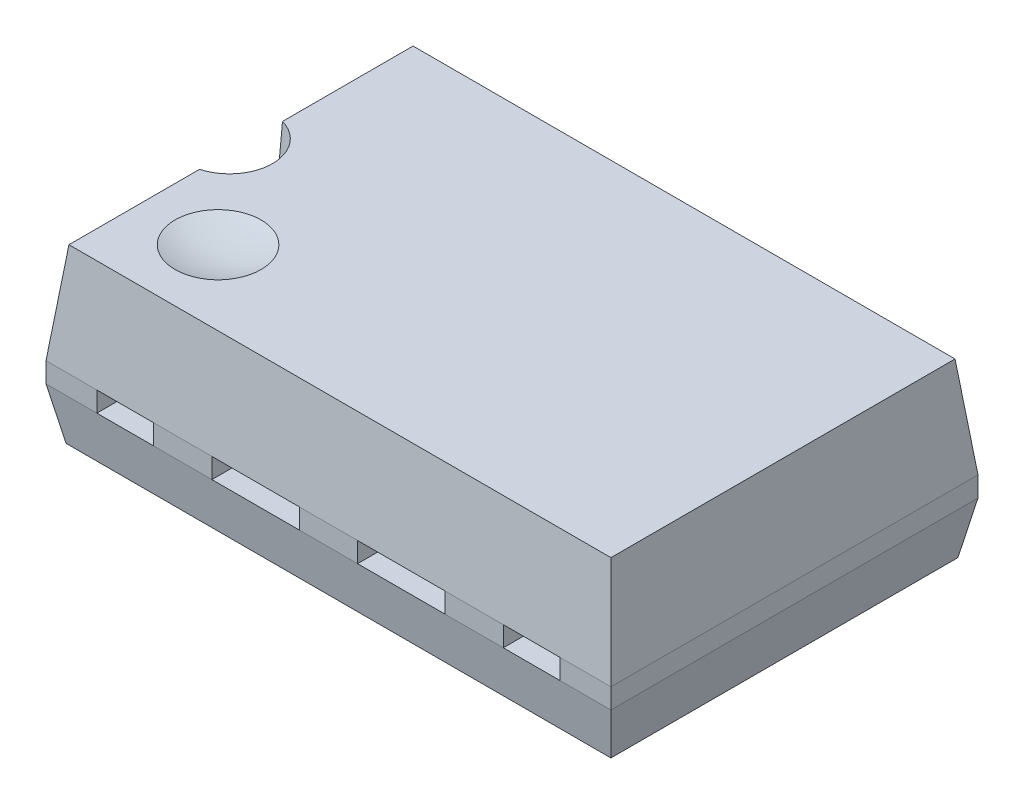
from build123d import *

# Parameters (mm, degrees)
SKETCH2_W      = 9.45
SKETCH2_H      = 6
SKETCH1_W      = 9.85
SKETCH1_H      = 6.4
SKETCH3_W      = 9.85
SKETCH3_H      = 6.4
EXTRUDE1_DEPTH = 0.35
SKETCH4_W      = 9.85
SKETCH4_H      = 6.4
SKETCH5_W      = 9.5
SKETCH5_H      = 6.05
SKETCH7_R      = 0.75
EXTRUDE2_DEPTH = 0.75
SKETCH11_W     = 1.524
SKETCH11_H     = 0.35
SKETCH11_W_2   = 0.9906
EXTRUDE3_DEPTH = 1


with BuildPart() as part:
    # Sketch2 → Loft1 section 0
    with BuildSketch(Plane(origin=(0, 1.75, 0), x_dir=(-1, 0, 0), z_dir=(0, 1, 0))):
        Rectangle(SKETCH2_W, SKETCH2_H)
    # Sketch1 → Loft1 section 1
    with BuildSketch(Plane(origin=(0, 0, 0), x_dir=(1, 0, 0), z_dir=(0, 1, 0))):
        Rectangle(SKETCH1_W, SKETCH1_H)
    loft()

    # Sketch3 → Extrude1 (add)
    with BuildSketch(Plane.XZ):
        Rectangle(SKETCH3_W, SKETCH3_H)
    extrude(amount=EXTRUDE1_DEPTH)

    # Sketch4 → Loft2 section 0
    with BuildSketch(Plane.XZ.offset(0.35)):
        Rectangle(SKETCH4_W, SKETCH4_H)
    # Sketch5 → Loft2 section 1
    with BuildSketch(Plane(origin=(0, -1.25, 0), x_dir=(-1, 0, 0), z_dir=(0, 1, 0))):
        Rectangle(SKETCH5_W, SKETCH5_H)
    loft()

    # Sketch7 → Extrude2 (cut)
    with BuildSketch(Plane(origin=(0, 1.75, 0), x_dir=(1, 0, 0), z_dir=(0, 1, 0))):
        with Locations((-4.925, 0)):
            Circle(SKETCH7_R)
    extrude(amount=-EXTRUDE2_DEPTH, mode=Mode.SUBTRACT)

    # Sketch10 → Cut-Revolve1 (revolve, cut)
    with BuildSketch(Plane.XY.offset(1.7)):
        with BuildLine():
            Line((-3.425, 6.25), (-3.425, 1.625))
            ThreePointArc((-3.425, 1.625), (-5.7375, 3.9375), (-3.425, 6.25))
        make_face()
    revolve(axis=Axis((-3.425, 6.25, 1.7), (0, -1, 0)), mode=Mode.SUBTRACT)

    # Sketch11 → Extrude3 (cut)
    with BuildSketch(Plane.XY.offset(3.2)):
        with Locations((-1.27, -0.175)):
            Rectangle(SKETCH11_W, SKETCH11_H)
        with Locations((1.27, -0.175)):
            Rectangle(SKETCH11_W, SKETCH11_H)
        with Locations((3.5433, -0.175)):
            Rectangle(SKETCH11_W_2, SKETCH11_H)
        with Locations((-3.5433, -0.175)):
            Rectangle(SKETCH11_W_2, SKETCH11_H)
    extrude3 = extrude(amount=-EXTRUDE3_DEPTH, mode=Mode.SUBTRACT)

    # Mirror1: Extrude3 across plane
    add(extrude3.mirror(Plane.XY), mode=Mode.SUBTRACT)


solid = part.part
